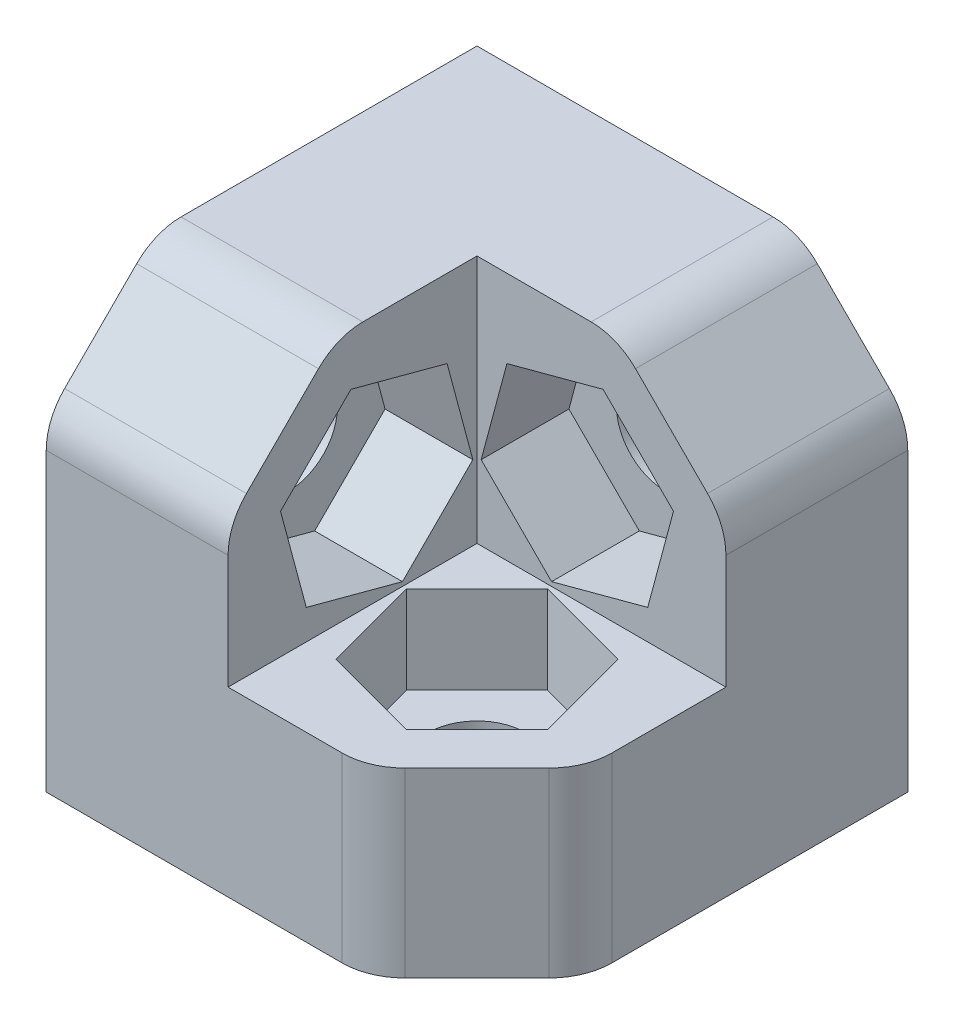
from build123d import *

# Parameters (mm, degrees)
IZIM1_W                     = 15
IZIM1_H                     = 15
IZIM1_R                     = 1.55
Y_KSEKLIK_EKSTR_ZYON1_DEPTH = 3
Y_KSEKLIK_EKSTR_ZYON2_DEPTH = 12
IZIM3_R                     = 1.55
KES_EKSTR_ZYON1_DEPTH       = 4
IZIM4_R                     = 1.55
KES_EKSTR_ZYON2_DEPTH       = 4
Y_KSEKLIK_EKSTR_ZYON3_DEPTH = 2.8
Y_KSEKLIK_EKSTR_ZYON4_DEPTH = 2.8
Y_KSEKLIK_EKSTR_ZYON5_DEPTH = 2.8
KES_EKSTR_ZYON3_DEPTH       = 3
KES_EKSTR_ZYON4_DEPTH       = 3
KES_EKSTR_ZYON5_DEPTH       = 3
IZIM13_W                    = 2.049280952
IZIM13_H                    = 12.849743754
KES_EKSTR_ZYON6_DEPTH       = 16
IZIM14_W                    = 1.259740945
IZIM14_H                    = 10.270148586
KES_EKSTR_ZYON7_DEPTH       = 16
IZIM15_W                    = 10.270148586
IZIM15_H                    = 1.259740945
KES_EKSTR_ZYON8_DEPTH       = 16
RADYUS1_R                   = 2


with BuildPart() as part:
    # Çizim1 → Yükseklik-Ekstrüzyon1 (new body)
    with BuildSketch(Plane.XY):
        with Locations((7.5, -7.5)):
            Rectangle(IZIM1_W, IZIM1_H)
        with Locations((9, -6)):
            Circle(IZIM1_R, mode=Mode.SUBTRACT)
    extrude(amount=Y_KSEKLIK_EKSTR_ZYON1_DEPTH)

    # Çizim2 → Yükseklik-Ekstrüzyon2 (add)
    with BuildSketch(Plane.XY.offset(3)):
        Polygon((0, 0), (0, -15), (15, -15), (15, -12), (3, -12), (3, 0), align=None)
    extrude(amount=Y_KSEKLIK_EKSTR_ZYON2_DEPTH)

    # Çizim3 → Kes-Ekstrüzyon1 (cut, through all)
    with BuildSketch(Plane(origin=(0, -12, 0), x_dir=(1, 0, 0), z_dir=(0, 1, 0))):
        with Locations((9, -9)):
            Circle(IZIM3_R)
    extrude(amount=-KES_EKSTR_ZYON1_DEPTH, mode=Mode.SUBTRACT)

    # Çizim4 → Kes-Ekstrüzyon2 (cut, through all)
    with BuildSketch(Plane(origin=(3, 0, 0), x_dir=(0, 0, -1), z_dir=(1, 0, 0))):
        with Locations((-9, -6)):
            Circle(IZIM4_R)
    extrude(amount=-KES_EKSTR_ZYON2_DEPTH, mode=Mode.SUBTRACT)

    # Çizim5 → Yükseklik-Ekstrüzyon3 (add)
    with BuildSketch(Plane.XY.offset(3)):
        Polygon((13.740259055, -4.729851414), (10.270148586, -1.259740945), (3, -1.259740945), (3, -12), (13.740259055, -12), align=None)
        Polygon((12.067226447, -5.178139151), (9.821860849, -2.932773553), (6.754634402, -3.754634402), (5.932773553, -6.821860849), (8.178139151, -9.067226447), (11.245365598, -8.245365598), align=None, mode=Mode.SUBTRACT)
    extrude(amount=Y_KSEKLIK_EKSTR_ZYON3_DEPTH)

    # Çizim6 → Yükseklik-Ekstrüzyon4 (add)
    with BuildSketch(Plane(origin=(0, -12, 0), x_dir=(1, 0, 0), z_dir=(0, 1, 0))):
        Polygon((10.270148586, -13.740259055), (13.740259055, -10.270148586), (13.740259055, -3), (3, -3), (3, -13.740259055), (5.529889531, -13.740259055), align=None)
        Polygon((12.067226447, -9.821860849), (11.245365598, -6.754634402), (8.178139151, -5.932773553), (5.932773553, -8.178139151), (6.754634402, -11.245365598), (9.821860849, -12.067226447), align=None, mode=Mode.SUBTRACT)
    extrude(amount=Y_KSEKLIK_EKSTR_ZYON4_DEPTH)

    # Çizim7 → Yükseklik-Ekstrüzyon5 (add)
    with BuildSketch(Plane(origin=(3, 0, 0), x_dir=(0, 0, -1), z_dir=(1, 0, 0))):
        Polygon((-10.270148586, -1.259740945), (-13.740259055, -4.729851414), (-13.740259055, -12), (-3, -12), (-3, -1.259740945), align=None)
        Polygon((-11.245365598, -8.245365598), (-8.178139151, -9.067226447), (-5.932773553, -6.821860849), (-6.754634402, -3.754634402), (-9.821860849, -2.932773553), (-12.067226447, -5.178139151), align=None, mode=Mode.SUBTRACT)
    extrude(amount=Y_KSEKLIK_EKSTR_ZYON5_DEPTH)

    # Çizim9 → Kes-Ekstrüzyon3 (cut)
    with BuildSketch(Plane.XY.offset(3)):
        Polygon((9.01040764, 0), (15, -5.98959236), (15, 0), align=None)
    extrude(amount=-KES_EKSTR_ZYON3_DEPTH, mode=Mode.SUBTRACT)

    # Çizim10 → Kes-Ekstrüzyon4 (cut)
    with BuildSketch(Plane(origin=(0, -12, 0), x_dir=(1, 0, 0), z_dir=(0, 1, 0))):
        Polygon((15, -9.01040764), (9.01040764, -15), (15, -15), align=None)
    extrude(amount=-KES_EKSTR_ZYON4_DEPTH, mode=Mode.SUBTRACT)

    # Çizim11 → Kes-Ekstrüzyon5 (cut)
    with BuildSketch(Plane(origin=(3, 0, 0), x_dir=(0, 0, -1), z_dir=(1, 0, 0))):
        Polygon((-9.01040764, 0), (-15, -5.98959236), (-15, 0), align=None)
    extrude(amount=-KES_EKSTR_ZYON5_DEPTH, mode=Mode.SUBTRACT)

    # Çizim13 → Kes-Ekstrüzyon6 (cut)
    with BuildSketch(Plane(origin=(15, 0, 0), x_dir=(0, 0, -1), z_dir=(1, 0, 0))):
        with Locations((-14.764899531, -9.373013496)):
            Rectangle(IZIM13_W, IZIM13_H)
    extrude(amount=-KES_EKSTR_ZYON6_DEPTH, mode=Mode.SUBTRACT)

    # Çizim14 → Kes-Ekstrüzyon7 (cut)
    with BuildSketch(Plane.XY.offset(13.740259055)):
        with Locations((14.370129528, -9.864925707)):
            Rectangle(IZIM14_W, IZIM14_H)
    extrude(amount=-KES_EKSTR_ZYON7_DEPTH, mode=Mode.SUBTRACT)

    # Çizim15 → Kes-Ekstrüzyon8 (cut)
    with BuildSketch(Plane(origin=(13.740259055, 0, 0), x_dir=(0, 0, -1), z_dir=(1, 0, 0))):
        with Locations((-5.135074293, -0.629870473)):
            Rectangle(IZIM15_W, IZIM15_H)
    extrude(amount=-KES_EKSTR_ZYON8_DEPTH, mode=Mode.SUBTRACT)

    # Radyus1
    radyus1_edges = [part.edges().sort_by_distance(p)[0] for p in [
        (2.9, -4.729851414, 13.740259055),
        (2.9, -1.259740945, 10.270148586),
        (13.740259055, -4.729851414, 2.9),
        (10.270148586, -1.259740945, 2.9),
        (13.740259055, -12.1, 10.270148586),
        (10.270148586, -12.1, 13.740259055),
    ]]
    fillet(radyus1_edges, radius=RADYUS1_R)


solid = part.part
